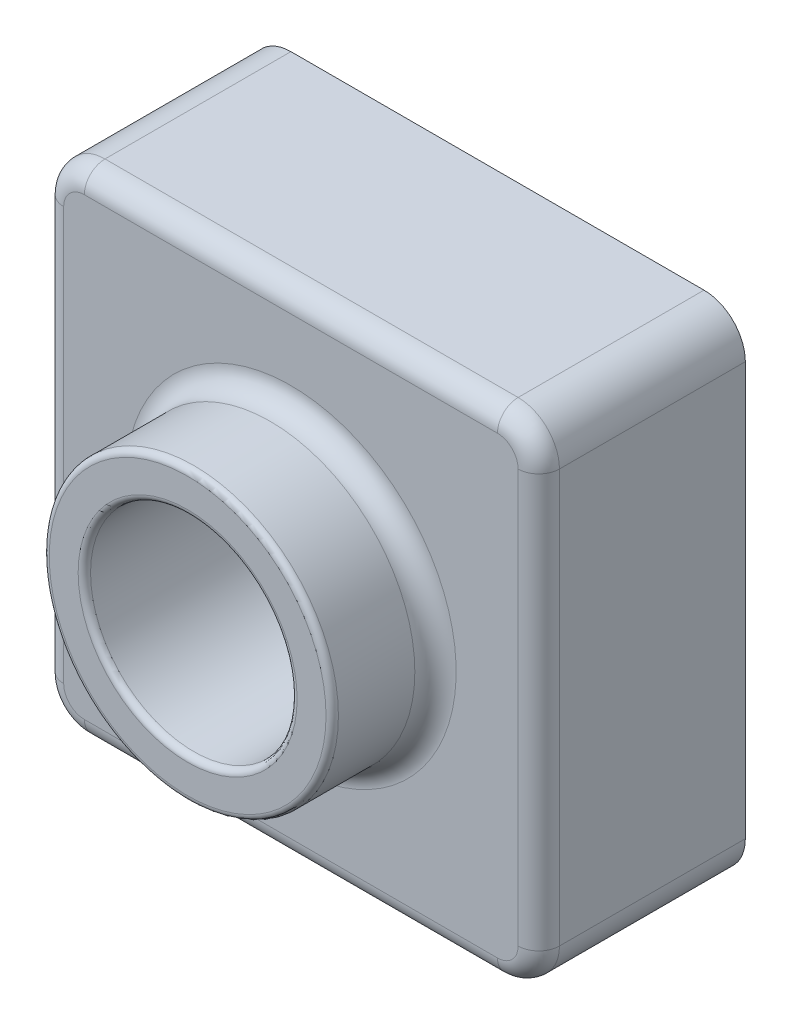
from build123d import *

# Parameters (mm, degrees)
SKETCH1_W           = 120
SKETCH1_H           = 120
BOSS_EXTRUDE1_DEPTH = 50
SKETCH2_R           = 35
BOSS_EXTRUDE2_DEPTH = 25
SKETCH3_R           = 25
CUT_EXTRUDE1_DEPTH  = 76
FILLET1_R           = 10
FILLET2_R           = 1.5
FILLET3_R           = 5
SHELL1_T            = -2


with BuildPart() as part:
    # Sketch1 → Boss-Extrude1 (new body)
    with BuildSketch(Plane.XY):
        with Locations((60, 60)):
            Rectangle(SKETCH1_W, SKETCH1_H)
    extrude(amount=BOSS_EXTRUDE1_DEPTH)

    # Sketch2 → Boss-Extrude2 (add)
    with BuildSketch(Plane.XY.offset(50)):
        with Locations((60, 60)):
            Circle(SKETCH2_R)
    extrude(amount=BOSS_EXTRUDE2_DEPTH)

    # Sketch3 → Cut-Extrude1 (cut, through all)
    with BuildSketch(Plane.XY.offset(75)):
        with Locations((60, 60)):
            Circle(SKETCH3_R)
    extrude(amount=-CUT_EXTRUDE1_DEPTH, mode=Mode.SUBTRACT)

    # Fillet1
    fillet1_edges = [part.edges().sort_by_distance(p)[0] for p in [
        (0, 120, 25),
        (120, 120, 25),
        (120, 0, 25),
        (0, 0, 25),
    ]]
    fillet(fillet1_edges, radius=FILLET1_R)

    # Fillet2
    fillet2_edges = [part.edges().sort_by_distance(p)[0] for p in [
        (25, 60, 75),
        (35, 60, 75),
    ]]
    fillet(fillet2_edges, radius=FILLET2_R)

    # Fillet3
    fillet3_edges = [part.edges().sort_by_distance(p)[0] for p in [
        (25, 60, 50),
        (60, 0, 50),
        (0, 60, 50),
        (120, 60, 50),
        (60, 120, 50),
        (117.071067812, 117.071067812, 50),
        (2.928932188, 117.071067812, 50),
        (117.071067812, 2.928932188, 50),
        (2.928932188, 2.928932188, 50),
    ]]
    fillet(fillet3_edges, radius=FILLET3_R)

    # Shell1
    shell1_openings = [part.faces().sort_by_distance(p)[0] for p in [
        (85, 60, 0),
    ]]
    offset(amount=SHELL1_T, openings=shell1_openings, kind=Kind.INTERSECTION)


solid = part.part
